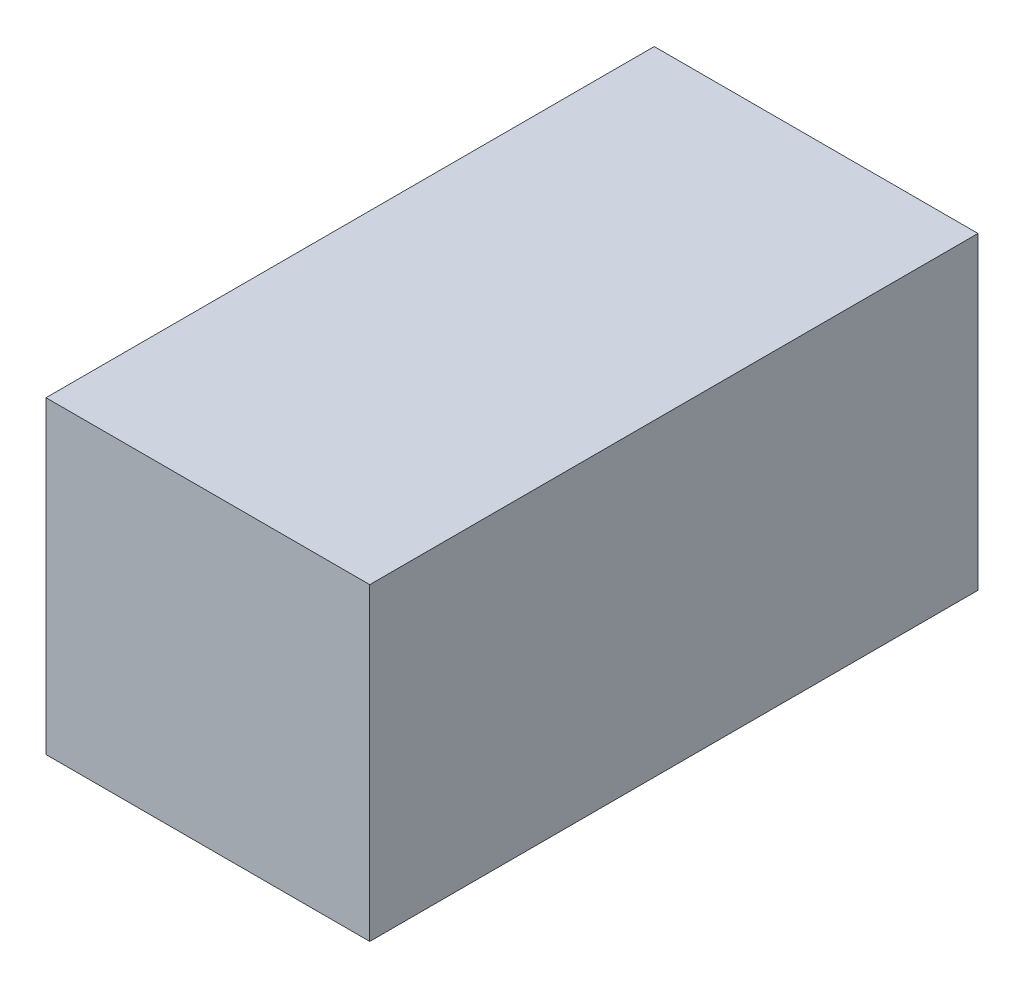
from build123d import *

# Parameters (mm, degrees)
BOSS_EXTRUDE1_START = 120
SKETCH1_W           = 660
SKETCH1_H           = 630
BOSS_EXTRUDE1_DEPTH = 1240


with BuildPart() as part:
    # Sketch1 → Boss-Extrude1 (new body)
    with BuildSketch(Plane.XY.offset(38871.700196057).offset(BOSS_EXTRUDE1_START)):
        with Locations((-18879.835057343, -7427.935150401)):
            Rectangle(SKETCH1_W, SKETCH1_H)
    extrude(amount=BOSS_EXTRUDE1_DEPTH)


solid = part.part
